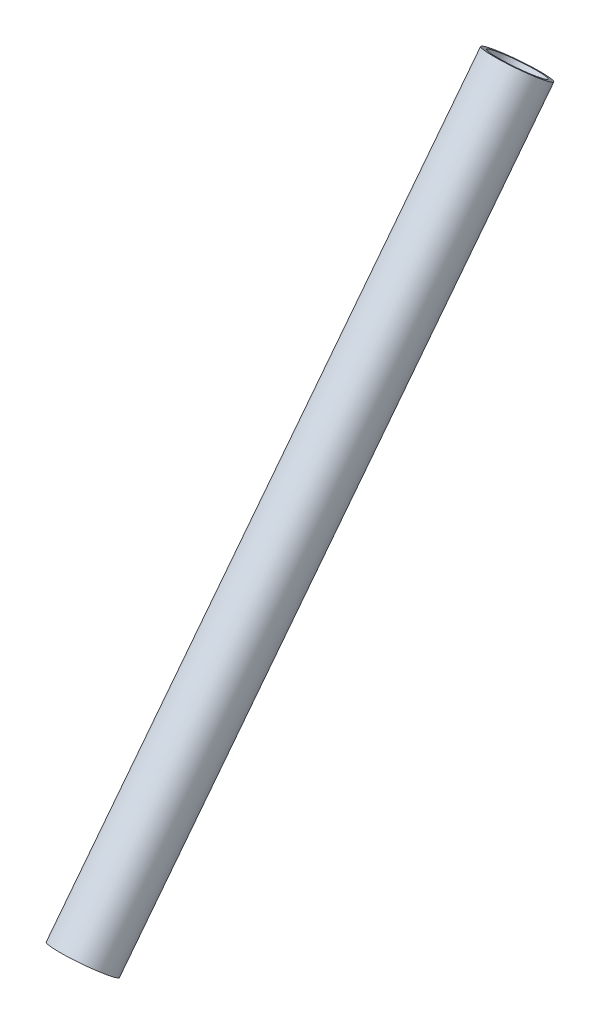
from build123d import *

# Parameters (mm, degrees)
SWEEP_THIN1_PROFILE_R   = 6.35
SWEEP_THIN1_PROFILE_R_2 = 5.35


with BuildPart() as part:
    # Sweep-Thin1: sweep along a curve in space
    with BuildLine() as sweep_thin1_path:
        Line((709.53, 493.285000015, 61.401866262), (709.53, 370.154999985, 157.178133738))
    # Sweep-Thin1 profile (on start of the path) → Sweep-Thin1 (sweep)
    with BuildSketch(Plane(origin=(709.53, 493.285000015, 61.401866262), x_dir=(0, -0.6139745227437846, -0.7893258423626721), z_dir=(0, -0.7893258423626721, 0.6139745227437846))):
        Circle(SWEEP_THIN1_PROFILE_R)
        Circle(SWEEP_THIN1_PROFILE_R_2, mode=Mode.SUBTRACT)
    sweep(path=sweep_thin1_path.line)


solid = part.part
